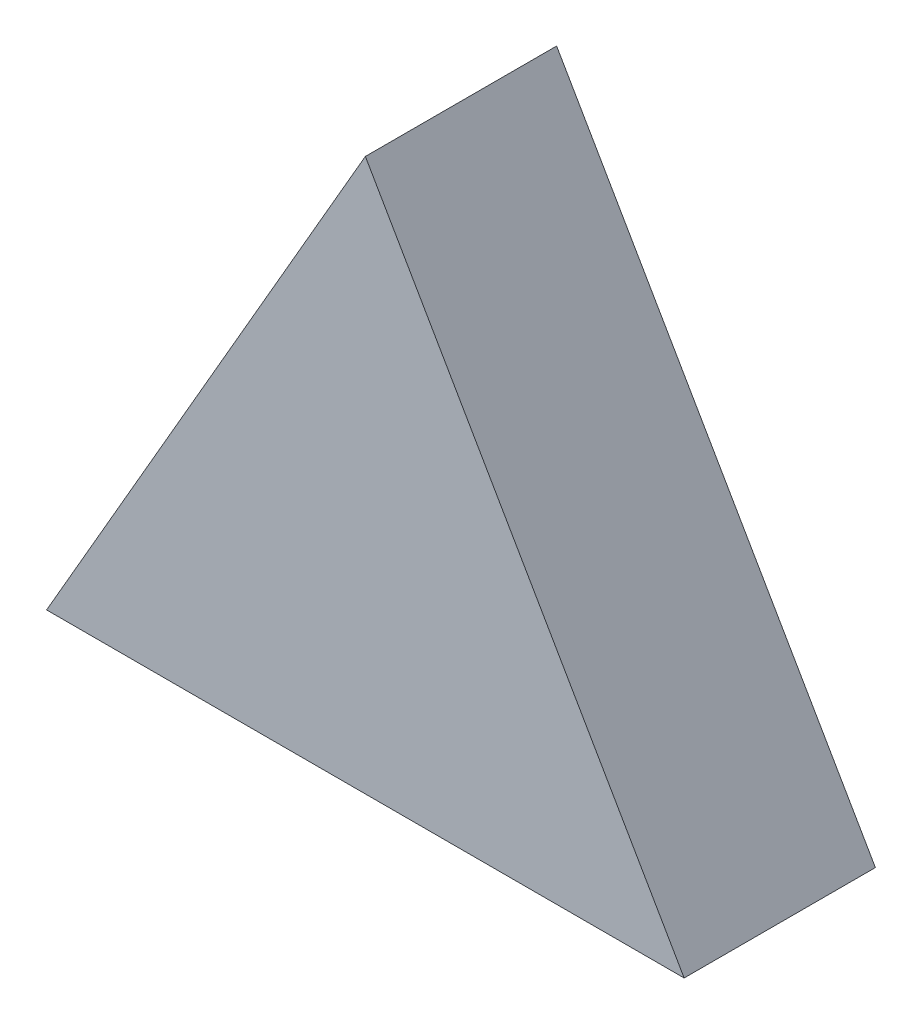
from build123d import *

# Parameters (mm, degrees)
BOSS_EXTRUDE1_DEPTH = 6


with BuildPart() as part:
    # Sketch1 → Boss-Extrude1 (new body)
    with BuildSketch(Plane.XY):
        Polygon((0, 17.320508076), (10, 0), (-10, 0), align=None)
    extrude(amount=BOSS_EXTRUDE1_DEPTH)


solid = part.part
